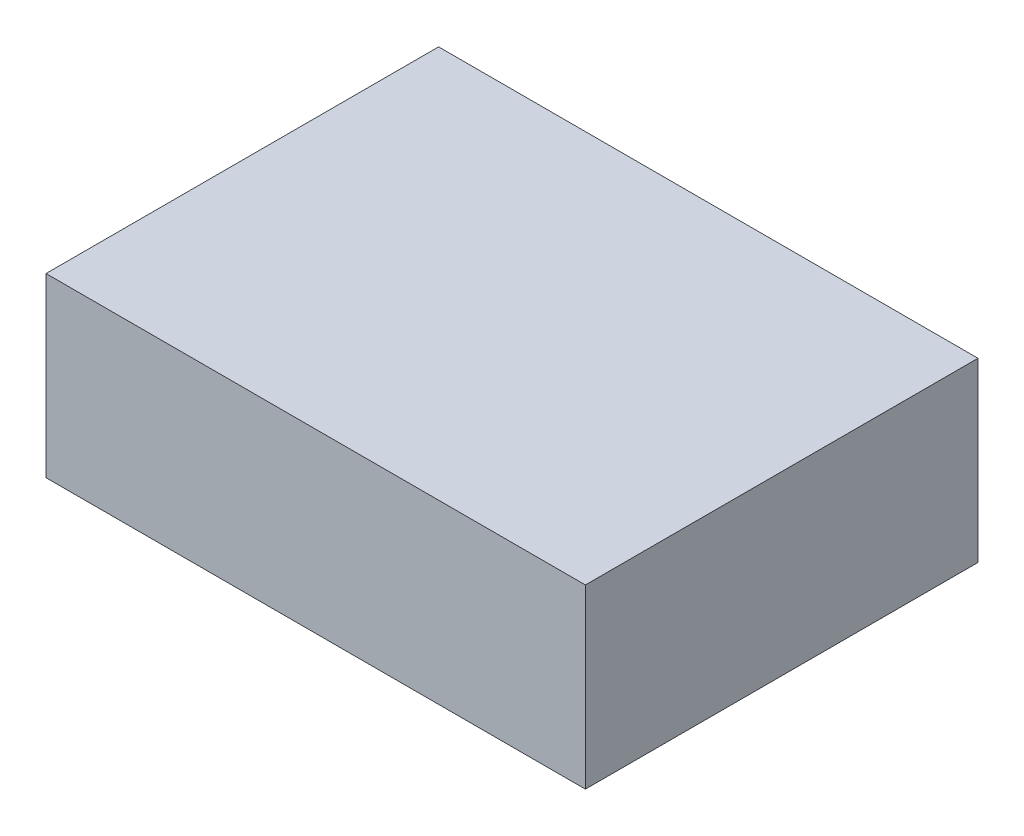
from build123d import *

# Parameters (mm, degrees)
SKETCH1_W           = 30.5
SKETCH1_H           = 22.2
BOSS_EXTRUDE1_DEPTH = 10


with BuildPart() as part:
    # Sketch1 → Boss-Extrude1 (new body)
    with BuildSketch(Plane(origin=(0, 0, 0), x_dir=(1, 0, 0), z_dir=(0, 1, 0))):
        with Locations((-22.918541199, 55.047294642)):
            Rectangle(SKETCH1_W, SKETCH1_H)
    extrude(amount=BOSS_EXTRUDE1_DEPTH)


solid = part.part
